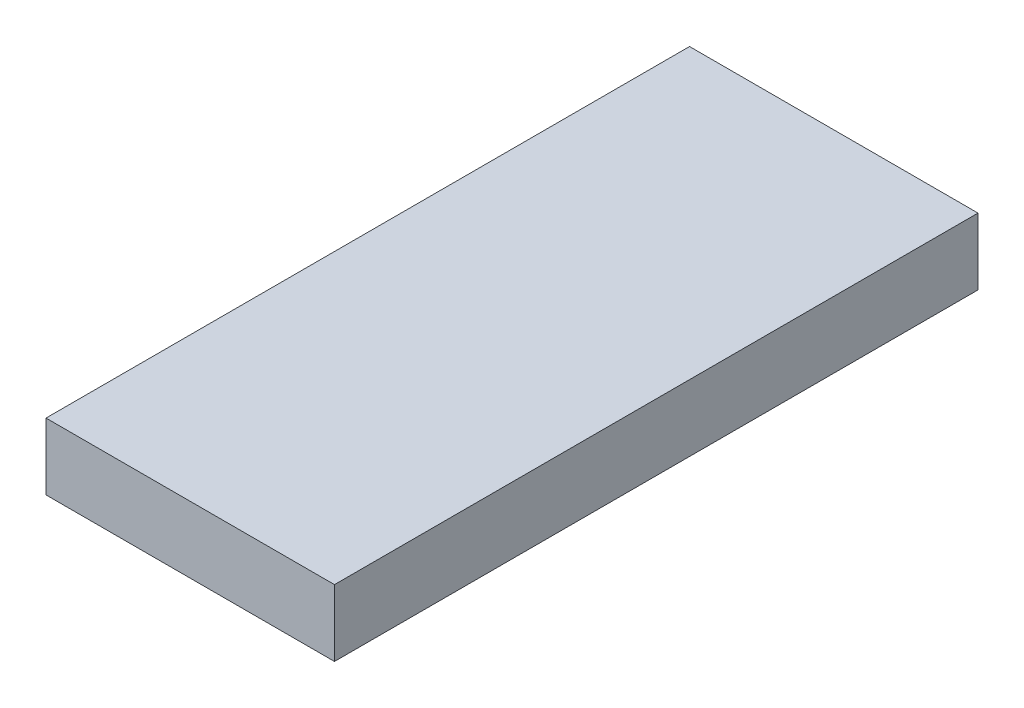
from build123d import *

# Parameters (mm, degrees)
SKETCH1_W           = 81.25
SKETCH1_H           = 181.25
BOSS_EXTRUDE1_DEPTH = 18.75


with BuildPart() as part:
    # Sketch1 → Boss-Extrude1 (new body)
    with BuildSketch(Plane(origin=(0, 0, 0), x_dir=(1, 0, 0), z_dir=(0, 1, 0))):
        with Locations((6.108318536, -71.095000942)):
            Rectangle(SKETCH1_W, SKETCH1_H)
    extrude(amount=BOSS_EXTRUDE1_DEPTH)


solid = part.part
